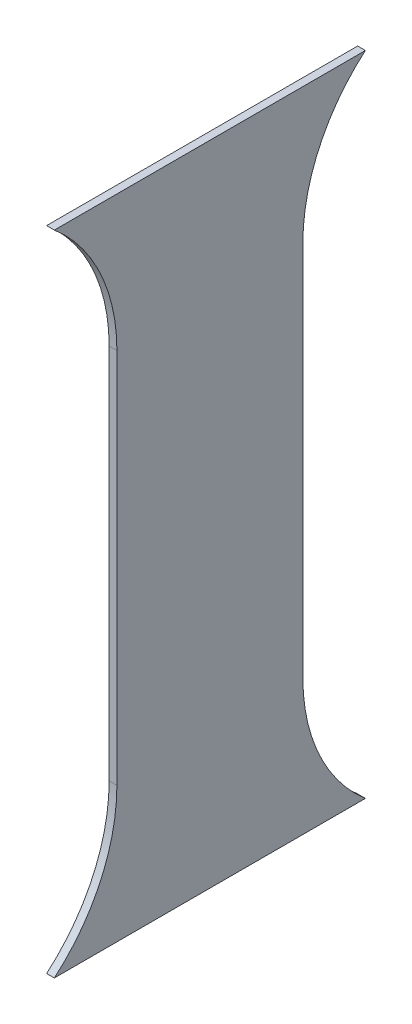
from build123d import *

# Parameters (mm, degrees)
BOSS_EXTRUDE1_DEPTH = 20
CUT_EXTRUDE1_DEPTH  = 20


with BuildPart() as part:
    # Sketch1 → Boss-Extrude1 (new body)
    with BuildSketch(Plane(origin=(0, 0, 0), x_dir=(0, 0, -1), z_dir=(1, 0, 0))):
        with BuildLine():
            Line((0, 0), (0, 972))
            ThreePointArc((0, 972), (-134.730880654, 1297.269119346), (-460, 1432))
            Line((-460, 1432), (940, 1432))
            ThreePointArc((940, 1432), (614.730880654, 1297.269119346), (480, 972))
            Line((480, 972), (480, 0))
            ThreePointArc((480, 0), (614.730880654, -325.269119346), (940, -460))
            Line((940, -460), (-460, -460))
            ThreePointArc((-460, -460), (-134.730880654, -325.269119346), (0, 0))
        make_face()
    extrude(amount=BOSS_EXTRUDE1_DEPTH)

    # Sketch2 → Cut-Extrude1 (cut)
    with BuildSketch(Plane(origin=(20, 0, 0), x_dir=(0, 0, -1), z_dir=(1, 0, 0))):
        Polygon((-460, 1322), (1004.695967819, 1322), (1004.695967819, 1530.227687148), (-489.352876869, 1530.227687148), align=None)
        Polygon((1004.695967819, -350), (1004.695967819, -558.227687148), (-489.352876869, -558.227687148), (-460, -350), align=None)
    extrude(amount=-CUT_EXTRUDE1_DEPTH, mode=Mode.SUBTRACT)


solid = part.part
